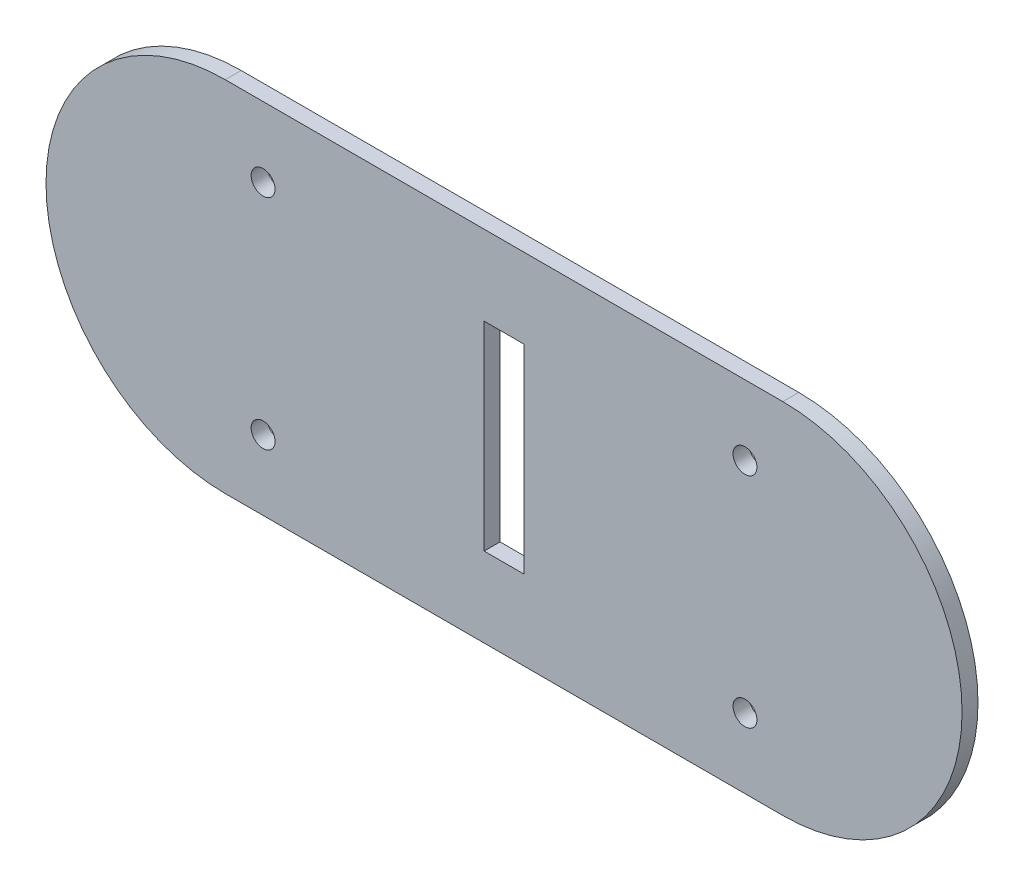
from build123d import *

# Parameters (mm, degrees)
DODANIE_WYCI_GNI_CIE1_DEPTH = 2
SZKIC2_R                    = 1.5
WYTNIJ_WYCI_GNI_CIE1_DEPTH  = 2
SZKIC4_W                    = 5
SZKIC4_H                    = 25
WYTNIJ_WYCI_GNI_CIE2_DEPTH  = 10


with BuildPart() as part:
    # Szkic1 → Dodanie-wyciągnięcie1 (new body)
    with BuildSketch(Plane.XY.offset(188.475370577)):
        with BuildLine():
            Line((90.164601585, 189.557553235), (20.164601585, 189.557553235))
            ThreePointArc((20.164601585, 189.557553235), (-2.335398415, 212.057553235), (20.164601585, 234.557553235))
            Line((20.164601585, 234.557553235), (90.164601585, 234.557553235))
            ThreePointArc((90.164601585, 234.557553235), (112.664601585, 212.057553235), (90.164601585, 189.557553235))
        make_face()
    extrude(amount=DODANIE_WYCI_GNI_CIE1_DEPTH)

    # Szkic2 → Wytnij-wyciągnięcie1 (cut)
    with BuildSketch(Plane.XY.offset(190.475370577)):
        with Locations((85.411548148, 225.777306357)):
            Circle(SZKIC2_R)
        with Locations((24.917655023, 225.777306357)):
            Circle(SZKIC2_R)
        with Locations((24.917655023, 198.337800113)):
            Circle(SZKIC2_R)
        with Locations((85.411548148, 198.337800113)):
            Circle(SZKIC2_R)
    extrude(amount=-WYTNIJ_WYCI_GNI_CIE1_DEPTH, mode=Mode.SUBTRACT)

    # Szkic4 → Wytnij-wyciągnięcie2 (cut)
    with BuildSketch(Plane.XY.offset(190.475370577)):
        with Locations((55.164601585, 212.057553235)):
            Rectangle(SZKIC4_W, SZKIC4_H)
    extrude(amount=-WYTNIJ_WYCI_GNI_CIE2_DEPTH, mode=Mode.SUBTRACT)


solid = part.part
